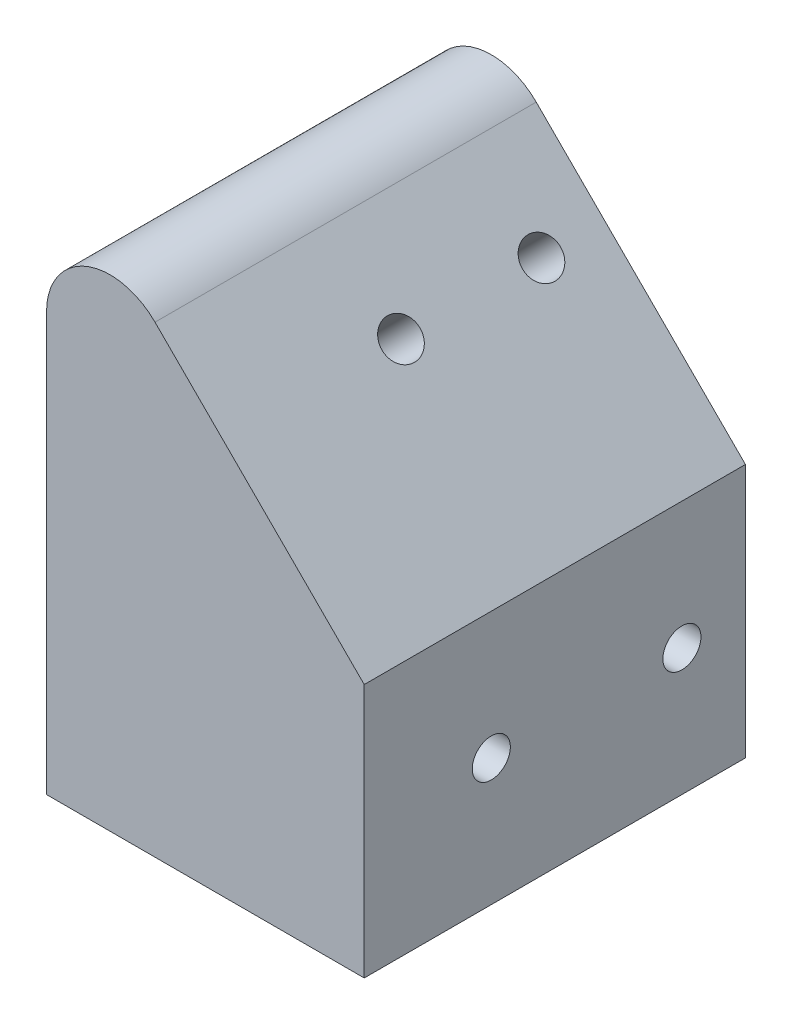
from build123d import *

# Parameters (mm, degrees)
CROQUIS2_W              = 30
CROQUIS2_H              = 20
SALIENTE_EXTRUIR2_DEPTH = 25
SALIENTE_EXTRUIR3_DEPTH = 30
REDONDEO1_R             = 5
CROQUIS8_R              = 1.5
CORTAR_EXTRUIR5_DEPTH   = 26
CROQUIS9_R              = 1.5
CORTAR_EXTRUIR6_DEPTH   = 32.819805153


with BuildPart() as part:
    # Croquis2 → Saliente-Extruir2 (new body)
    with BuildSketch(Plane(origin=(0, 0, 0), x_dir=(0, 0, -1), z_dir=(1, 0, 0))):
        with Locations((-15, -10)):
            Rectangle(CROQUIS2_W, CROQUIS2_H)
    extrude(amount=SALIENTE_EXTRUIR2_DEPTH)

    # Croquis3 → Saliente-Extruir3 (add, through all)
    with BuildSketch(Plane(origin=(0, 0, 0), x_dir=(-1, 0, 0), z_dir=(0, 0, -1))):
        Polygon((0, 0), (0, 25), (-25, 0), align=None)
    extrude(amount=-SALIENTE_EXTRUIR3_DEPTH)

    # Redondeo1
    redondeo1_edges = [part.edges().sort_by_distance(p)[0] for p in [
        (0, 25, 15),
    ]]
    fillet(redondeo1_edges, radius=REDONDEO1_R)

    # Croquis8 → Cortar-Extruir5 (cut, through all)
    with BuildSketch(Plane.ZY):
        with Locations((20, -10)):
            Circle(CROQUIS8_R)
        with Locations((5, -10)):
            Circle(CROQUIS8_R)
    extrude(amount=-CORTAR_EXTRUIR5_DEPTH, mode=Mode.SUBTRACT)

    # Croquis9 → Cortar-Extruir6 (cut, through all)
    with BuildSketch(Plane(origin=(12.5, 12.5, 0), x_dir=(0, 0, -1), z_dir=(0.707106781, 0.707106781, 0))):
        with Locations((-16.056627864, -2.050053866)):
            Circle(CROQUIS9_R)
        with Locations((-5.000664805, -2.050053866)):
            Circle(CROQUIS9_R)
    extrude(amount=-CORTAR_EXTRUIR6_DEPTH, mode=Mode.SUBTRACT)


solid = part.part
